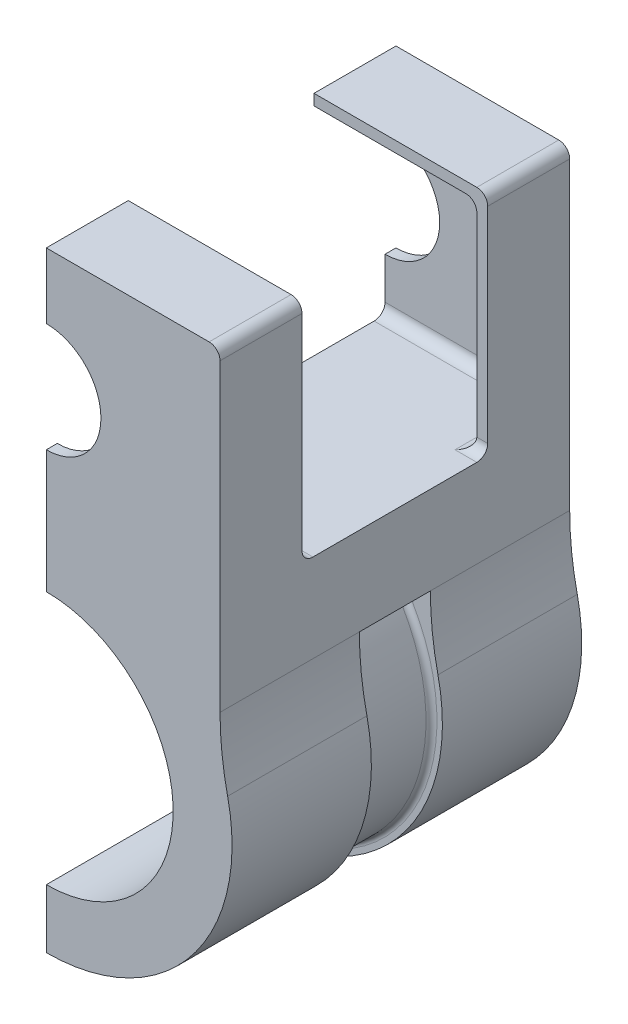
from build123d import *

# Parameters (mm, degrees)
BOSS_EXTRUDE1_DEPTH            = 81.28
SKETCH3_W                      = 76.2
SKETCH3_H                      = 50.292
CUT_EXTRUDE1_DEPTH             = 37.846
SKETCH4_W                      = 40.386
SKETCH4_H                      = 43.18
CUT_EXTRUDE2_DEPTH             = 52.832
FILLET1_R                      = 2.54
FILLET2_R                      = 2.54
FILLET3_R                      = 2.54
FILLET4_R                      = 2.54
SKETCH7_W                      = 16.51
SKETCH7_H                      = 2.54
CUT_EXTRUDE4_REACH             = 54.566
SKETCH8_W                      = 16.51
SKETCH8_H                      = 16.012242806
CUT_EXTRUDE4_DIRECTION_2_DEPTH = 2.54
FILLET5_R                      = 1.27


with BuildPart() as part:
    # Sketch1 → Boss-Extrude1 (new body)
    with BuildSketch(Plane.XY):
        with BuildLine():
            Line((0, 52.9844), (0, 58.0644))
            ThreePointArc((0, 58.0644), (12.7, 70.7644), (0, 83.4644))
            Line((0, 83.4644), (0, 98.7044))
            Line((0, 98.7044), (40.386, 98.7044))
            Line((40.386, 98.7044), (40.386, 25.398729968))
            ThreePointArc((40.386, 25.398729968), (40.827682914, 17.344312358), (42.147434783, 9.386487162))
            ThreePointArc((42.147434783, 9.386487162), (33.688432107, -27.011144777), (0, -43.18))
            Line((0, -43.18), (0, -29.4894))
            ThreePointArc((0, -29.4894), (29.4894, 0), (0, 29.4894))
            Line((0, 29.4894), (0, 52.9844))
        make_face()
    extrude(amount=-BOSS_EXTRUDE1_DEPTH)

    # Sketch3 → Cut-Extrude1 (cut)
    with BuildSketch(Plane.ZY):
        with Locations((-40.64, 71.0184)):
            Rectangle(SKETCH3_W, SKETCH3_H)
    extrude(amount=-CUT_EXTRUDE1_DEPTH, mode=Mode.SUBTRACT)

    # Sketch4 → Cut-Extrude2 (cut)
    with BuildSketch(Plane(origin=(0, 98.7044, 0), x_dir=(1, 0, 0), z_dir=(0, 1, 0))):
        with Locations((20.193, 40.64)):
            Rectangle(SKETCH4_W, SKETCH4_H)
    extrude(amount=-CUT_EXTRUDE2_DEPTH, mode=Mode.SUBTRACT)

    # Fillet1
    fillet1_edges = [part.edges().sort_by_distance(p)[0] for p in [
        (18.923, 45.8724, -78.74),
        (18.923, 45.8724, -2.54),
        (37.846, 45.8724, -10.795),
        (37.846, 45.8724, -70.485),
    ]]
    fillet(fillet1_edges, radius=FILLET1_R)

    # Fillet2
    fillet2_edges = [part.edges().sort_by_distance(p)[0] for p in [
        (37.846, 96.1644, -70.485),
        (37.846, 96.1644, -10.795),
    ]]
    fillet(fillet2_edges, radius=FILLET2_R)

    # Fillet3
    fillet3_edges = [part.edges().sort_by_distance(p)[0] for p in [
        (36.576, 45.8724, -19.05),
        (36.576, 45.8724, -62.23),
    ]]
    fillet(fillet3_edges, radius=FILLET3_R)

    # Fillet4
    fillet4_edges = [part.edges().sort_by_distance(p)[0] for p in [
        (40.386, 98.7044, -71.755),
        (40.386, 98.7044, -9.525),
    ]]
    fillet(fillet4_edges, radius=FILLET4_R)

    # Sketch7 → Cut-Revolve2 (revolve, cut)
    with BuildSketch(Plane.ZY):
        with Locations((-40.64, -41.91)):
            Rectangle(SKETCH7_W, SKETCH7_H)
    revolve(axis=Axis((0, 0, -81.28), (0, 0, 1)), mode=Mode.SUBTRACT)

    # Sketch8 → Cut-Extrude4 (cut, up to next)
    with BuildSketch(Plane(origin=(42.147434783, 9.386487162, 0), x_dir=(0, 0, -1), z_dir=(0.976086957, 0.217380435, 0)), mode=Mode.PRIVATE) as cut_extrude4_sk1:
        with Locations((40.64, 8.006121403)):
            Rectangle(SKETCH8_W, SKETCH8_H)
    cut_extrude4_tool1 = extrude(cut_extrude4_sk1.sketch, amount=-CUT_EXTRUDE4_REACH, mode=Mode.PRIVATE) & part.part
    add(cut_extrude4_tool1.solids().sort_by_distance((40.407061, 17.201158, -40.64))[0], mode=Mode.SUBTRACT)

    # Sketch8 → Cut-Extrude4 direction 2 (cut)
    with BuildSketch(Plane(origin=(42.147434783, 9.386487162, 0), x_dir=(0, 0, -1), z_dir=(0.976086957, 0.217380435, 0))):
        with Locations((40.64, 8.006121403)):
            Rectangle(SKETCH8_W, SKETCH8_H)
    extrude(amount=CUT_EXTRUDE4_DIRECTION_2_DEPTH, mode=Mode.SUBTRACT)

    # Fillet5
    fillet5_edges = [part.edges().sort_by_distance(p)[0] for p in [
        (40.64, 0, -48.895),
        (40.64, 0, -32.385),
    ]]
    fillet(fillet5_edges, radius=FILLET5_R)


solid = part.part
